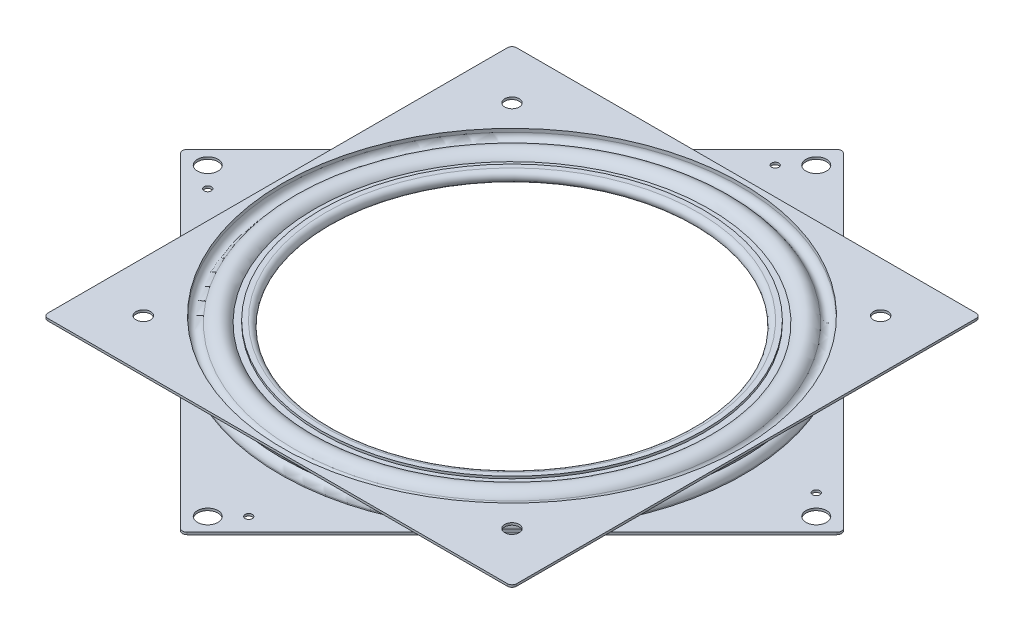
from build123d import *

# Parameters (mm, degrees)
BOSS_EXTRUDE1_START     = -0.7366
SKETCH4_W               = 153.924
SKETCH4_H               = 153.924
SKETCH4_R               = 75.348209056
BOSS_EXTRUDE1_DEPTH     = 0.7366
BOSS_EXTRUDE2_START     = -0.736601
SKETCH5_R               = 75.348209056
BOSS_EXTRUDE2_DEPTH     = 0.736602
SKETCH6_R               = 2.38125
CUT_EXTRUDE1_DEPTH      = 4.9370001
CUT_EXTRUDE1_DEPTH_BACK = 4.937001
SKETCH7_R               = 3.3734375
SKETCH7_R_2             = 1.1922125
CUT_EXTRUDE2_DEPTH      = 4.9370001
CUT_EXTRUDE2_DEPTH_BACK = 4.937001
CIRPATTERN1_COUNT       = 50
FILLET1_R               = 1.53924
FILLET2_R               = 1.53924


with BuildPart() as part:
    # Sketch3 → Revolve-Thin1 (revolve)
    with BuildSketch(Plane.XY):
        with BuildLine():
            Line((76.962, -3.937), (75.348209056, -3.937))
            Line((75.348209056, -3.937), (75.348209056, -2.83464))
            ThreePointArc((75.348209056, -2.83464), (73.867348091, -0.927495427), (71.652806037, -1.88976))
            ThreePointArc((71.652806037, -1.88976), (67.651879497, -3.898798296), (64.358457004, -0.86614))
            Line((64.358457004, -0.86614), (61.20765, -0.86614))
            ThreePointArc((61.20765, -0.86614), (59.436, 0.90551), (61.20765, 2.67716))
            Line((61.20765, 2.67716), (62.783053502, 2.67716))
            Line((62.783053502, 2.67716), (62.783053502, 1.94056))
            Line((62.783053502, 1.94056), (61.20765, 1.94056))
            ThreePointArc((61.20765, 1.94056), (60.1726, 0.90551), (61.20765, -0.12954))
            Line((61.20765, -0.12954), (65.001222718, -0.12954))
            ThreePointArc((65.001222718, -0.12954), (67.469119821, -3.116060828), (71.006610069, -1.536192))
            ThreePointArc((71.006610069, -1.536192), (74.049819472, -0.213854232), (76.084809056, -2.83464))
            Line((76.084809056, -2.83464), (76.084809056, -3.2004))
            Line((76.084809056, -3.2004), (76.962, -3.2004))
            Line((76.962, -3.2004), (76.962, -3.937))
        make_face()
    revolve(axis=Axis((0, 3.937, 0), (0, -1, 0)))

    # Sketch5 → Boss-Extrude2 (add)
    with BuildSketch(Plane.XZ.offset(3.937).offset(BOSS_EXTRUDE2_START)):
        Polygon((-108.840704187, 0), (0, 108.840704187), (108.840704187, 0), (0, -108.840704187), align=None)
        Circle(SKETCH5_R, mode=Mode.SUBTRACT)
    extrude(amount=BOSS_EXTRUDE2_DEPTH)

    # Sketch7 → Cut-Extrude2 (cut, two sides)
    with BuildSketch(Plane(origin=(0, 0, 0), x_dir=(1, 0, 0), z_dir=(0, 1, 0))) as cut_extrude2_sk:
        with Locations((99.905349347, 0)):
            Circle(SKETCH7_R)
        with Locations((0, 99.905349347)):
            Circle(SKETCH7_R)
        with Locations((-99.905349347, 0)):
            Circle(SKETCH7_R)
        with Locations((0, -99.905349347)):
            Circle(SKETCH7_R)
        with Locations((6.735192091, -93.170157256)):
            Circle(SKETCH7_R_2)
        with Locations((-93.170157256, -6.735192091)):
            Circle(SKETCH7_R_2)
        with Locations((-6.735192091, 93.170157256)):
            Circle(SKETCH7_R_2)
        with Locations((93.170157256, 6.735192091)):
            Circle(SKETCH7_R_2)
    extrude(amount=CUT_EXTRUDE2_DEPTH, mode=Mode.SUBTRACT)
    extrude(cut_extrude2_sk.sketch, amount=-CUT_EXTRUDE2_DEPTH_BACK, mode=Mode.SUBTRACT)

    # Fillet2
    fillet2_edges = [part.edges().sort_by_distance(p)[0] for p in [
        (0, -3.5687, -108.840704187),
        (-108.840704187, -3.5687, 0),
        (0, -3.5687, 108.840704187),
        (108.840704187, -3.5687, 0),
    ]]
    fillet(fillet2_edges, radius=FILLET2_R)


with BuildPart() as body_2:
    # Sketch3_3 → Revolve-Thin2 (revolve)
    with BuildSketch(Plane.XY):
        with BuildLine():
            Line((76.962, 3.937), (75.348209056, 3.937))
            Line((75.348209056, 3.937), (75.348209056, 2.83464))
            ThreePointArc((75.348209056, 2.83464), (73.867348091, 0.927495427), (71.652806037, 1.88976))
            ThreePointArc((71.652806037, 1.88976), (68.228071759, 3.936892662), (64.773478742, 1.94056))
            Line((64.773478742, 1.94056), (61.20765, 1.94056))
            Line((61.20765, 1.94056), (61.20765, 1.20396))
            Line((61.20765, 1.20396), (65.233693864, 1.20396))
            ThreePointArc((65.233693864, 1.20396), (68.015120861, 3.195113241), (71.006610069, 1.536192))
            ThreePointArc((71.006610069, 1.536192), (74.049819472, 0.213854232), (76.084809056, 2.83464))
            Line((76.084809056, 2.83464), (76.084809056, 3.2004))
            Line((76.084809056, 3.2004), (76.962, 3.2004))
            Line((76.962, 3.2004), (76.962, 3.937))
        make_face()
    revolve(axis=Axis((0, 3.937, 0), (0, -1, 0)))

    # Sketch4 → Boss-Extrude1 (add)
    with BuildSketch(Plane(origin=(0, 3.937, 0), x_dir=(1, 0, 0), z_dir=(0, 1, 0)).offset(BOSS_EXTRUDE1_START)):
        Rectangle(SKETCH4_W, SKETCH4_H)
        Circle(SKETCH4_R, mode=Mode.SUBTRACT)
    extrude(amount=BOSS_EXTRUDE1_DEPTH)

    # Sketch6 → Cut-Extrude1 (cut, two sides)
    with BuildSketch(Plane(origin=(0, 0, 0), x_dir=(1, 0, 0), z_dir=(0, 1, 0))) as cut_extrude1_sk:
        with Locations((-60.5282, 60.5282)):
            Circle(SKETCH6_R)
        with Locations((-60.5282, -60.5282)):
            Circle(SKETCH6_R)
        with Locations((60.5282, -60.5282)):
            Circle(SKETCH6_R)
        with Locations((60.5282, 60.5282)):
            Circle(SKETCH6_R)
    extrude(amount=CUT_EXTRUDE1_DEPTH, mode=Mode.SUBTRACT)
    extrude(cut_extrude1_sk.sketch, amount=-CUT_EXTRUDE1_DEPTH_BACK, mode=Mode.SUBTRACT)

    # Fillet1
    fillet1_edges = [body_2.edges().sort_by_distance(p)[0] for p in [
        (-76.962, 3.5687, 76.962),
        (-76.962, 3.5687, -76.962),
        (76.962, 3.5687, -76.962),
        (76.962, 3.5687, 76.962),
    ]]
    fillet(fillet1_edges, radius=FILLET1_R)


with BuildPart() as body_3:
    # Sketch8 → Revolve1 (revolve)
    with BuildSketch(Plane.XY):
        with BuildLine():
            Line((68.199, -3.683), (68.199, 3.683))
            ThreePointArc((68.199, 3.683), (71.882, 0), (68.199, -3.683))
        make_face()
    revolve(axis=Axis((68.199, -3.683, 0), (0, 1, 0)))


with BuildPart() as cirpattern1_1:
    # CirPattern1: pattern copy
    add(body_3.part.rotate(Axis((0, 0, 0), (0, 1, 0)), 1 * 360 / CIRPATTERN1_COUNT))


with BuildPart() as cirpattern1_2:
    # CirPattern1: pattern copy
    add(body_3.part.rotate(Axis((0, 0, 0), (0, 1, 0)), 2 * 360 / CIRPATTERN1_COUNT))


with BuildPart() as cirpattern1_3:
    # CirPattern1: pattern copy
    add(body_3.part.rotate(Axis((0, 0, 0), (0, 1, 0)), 3 * 360 / CIRPATTERN1_COUNT))


with BuildPart() as cirpattern1_4:
    # CirPattern1: pattern copy
    add(body_3.part.rotate(Axis((0, 0, 0), (0, 1, 0)), 4 * 360 / CIRPATTERN1_COUNT))


with BuildPart() as cirpattern1_5:
    # CirPattern1: pattern copy
    add(body_3.part.rotate(Axis((0, 0, 0), (0, 1, 0)), 5 * 360 / CIRPATTERN1_COUNT))


with BuildPart() as cirpattern1_6:
    # CirPattern1: pattern copy
    add(body_3.part.rotate(Axis((0, 0, 0), (0, 1, 0)), 6 * 360 / CIRPATTERN1_COUNT))


with BuildPart() as cirpattern1_7:
    # CirPattern1: pattern copy
    add(body_3.part.rotate(Axis((0, 0, 0), (0, 1, 0)), 7 * 360 / CIRPATTERN1_COUNT))


with BuildPart() as cirpattern1_8:
    # CirPattern1: pattern copy
    add(body_3.part.rotate(Axis((0, 0, 0), (0, 1, 0)), 8 * 360 / CIRPATTERN1_COUNT))


with BuildPart() as cirpattern1_9:
    # CirPattern1: pattern copy
    add(body_3.part.rotate(Axis((0, 0, 0), (0, 1, 0)), 9 * 360 / CIRPATTERN1_COUNT))


with BuildPart() as cirpattern1_10:
    # CirPattern1: pattern copy
    add(body_3.part.rotate(Axis((0, 0, 0), (0, 1, 0)), 10 * 360 / CIRPATTERN1_COUNT))


with BuildPart() as cirpattern1_11:
    # CirPattern1: pattern copy
    add(body_3.part.rotate(Axis((0, 0, 0), (0, 1, 0)), 11 * 360 / CIRPATTERN1_COUNT))


with BuildPart() as cirpattern1_12:
    # CirPattern1: pattern copy
    add(body_3.part.rotate(Axis((0, 0, 0), (0, 1, 0)), 12 * 360 / CIRPATTERN1_COUNT))


with BuildPart() as cirpattern1_13:
    # CirPattern1: pattern copy
    add(body_3.part.rotate(Axis((0, 0, 0), (0, 1, 0)), 13 * 360 / CIRPATTERN1_COUNT))


with BuildPart() as cirpattern1_14:
    # CirPattern1: pattern copy
    add(body_3.part.rotate(Axis((0, 0, 0), (0, 1, 0)), 14 * 360 / CIRPATTERN1_COUNT))


with BuildPart() as cirpattern1_15:
    # CirPattern1: pattern copy
    add(body_3.part.rotate(Axis((0, 0, 0), (0, 1, 0)), 15 * 360 / CIRPATTERN1_COUNT))


with BuildPart() as cirpattern1_16:
    # CirPattern1: pattern copy
    add(body_3.part.rotate(Axis((0, 0, 0), (0, 1, 0)), 16 * 360 / CIRPATTERN1_COUNT))


with BuildPart() as cirpattern1_17:
    # CirPattern1: pattern copy
    add(body_3.part.rotate(Axis((0, 0, 0), (0, 1, 0)), 17 * 360 / CIRPATTERN1_COUNT))


with BuildPart() as cirpattern1_18:
    # CirPattern1: pattern copy
    add(body_3.part.rotate(Axis((0, 0, 0), (0, 1, 0)), 18 * 360 / CIRPATTERN1_COUNT))


with BuildPart() as cirpattern1_19:
    # CirPattern1: pattern copy
    add(body_3.part.rotate(Axis((0, 0, 0), (0, 1, 0)), 19 * 360 / CIRPATTERN1_COUNT))


with BuildPart() as cirpattern1_20:
    # CirPattern1: pattern copy
    add(body_3.part.rotate(Axis((0, 0, 0), (0, 1, 0)), 20 * 360 / CIRPATTERN1_COUNT))


with BuildPart() as cirpattern1_21:
    # CirPattern1: pattern copy
    add(body_3.part.rotate(Axis((0, 0, 0), (0, 1, 0)), 21 * 360 / CIRPATTERN1_COUNT))


with BuildPart() as cirpattern1_22:
    # CirPattern1: pattern copy
    add(body_3.part.rotate(Axis((0, 0, 0), (0, 1, 0)), 22 * 360 / CIRPATTERN1_COUNT))


with BuildPart() as cirpattern1_23:
    # CirPattern1: pattern copy
    add(body_3.part.rotate(Axis((0, 0, 0), (0, 1, 0)), 23 * 360 / CIRPATTERN1_COUNT))


with BuildPart() as cirpattern1_24:
    # CirPattern1: pattern copy
    add(body_3.part.rotate(Axis((0, 0, 0), (0, 1, 0)), 24 * 360 / CIRPATTERN1_COUNT))


with BuildPart() as cirpattern1_25:
    # CirPattern1: pattern copy
    add(body_3.part.rotate(Axis((0, 0, 0), (0, 1, 0)), 25 * 360 / CIRPATTERN1_COUNT))


with BuildPart() as cirpattern1_26:
    # CirPattern1: pattern copy
    add(body_3.part.rotate(Axis((0, 0, 0), (0, 1, 0)), 26 * 360 / CIRPATTERN1_COUNT))


with BuildPart() as cirpattern1_27:
    # CirPattern1: pattern copy
    add(body_3.part.rotate(Axis((0, 0, 0), (0, 1, 0)), 27 * 360 / CIRPATTERN1_COUNT))


with BuildPart() as cirpattern1_28:
    # CirPattern1: pattern copy
    add(body_3.part.rotate(Axis((0, 0, 0), (0, 1, 0)), 28 * 360 / CIRPATTERN1_COUNT))


with BuildPart() as cirpattern1_29:
    # CirPattern1: pattern copy
    add(body_3.part.rotate(Axis((0, 0, 0), (0, 1, 0)), 29 * 360 / CIRPATTERN1_COUNT))


with BuildPart() as cirpattern1_30:
    # CirPattern1: pattern copy
    add(body_3.part.rotate(Axis((0, 0, 0), (0, 1, 0)), 30 * 360 / CIRPATTERN1_COUNT))


with BuildPart() as cirpattern1_31:
    # CirPattern1: pattern copy
    add(body_3.part.rotate(Axis((0, 0, 0), (0, 1, 0)), 31 * 360 / CIRPATTERN1_COUNT))


with BuildPart() as cirpattern1_32:
    # CirPattern1: pattern copy
    add(body_3.part.rotate(Axis((0, 0, 0), (0, 1, 0)), 32 * 360 / CIRPATTERN1_COUNT))


with BuildPart() as cirpattern1_33:
    # CirPattern1: pattern copy
    add(body_3.part.rotate(Axis((0, 0, 0), (0, 1, 0)), 33 * 360 / CIRPATTERN1_COUNT))


with BuildPart() as cirpattern1_34:
    # CirPattern1: pattern copy
    add(body_3.part.rotate(Axis((0, 0, 0), (0, 1, 0)), 34 * 360 / CIRPATTERN1_COUNT))


with BuildPart() as cirpattern1_35:
    # CirPattern1: pattern copy
    add(body_3.part.rotate(Axis((0, 0, 0), (0, 1, 0)), 35 * 360 / CIRPATTERN1_COUNT))


with BuildPart() as cirpattern1_36:
    # CirPattern1: pattern copy
    add(body_3.part.rotate(Axis((0, 0, 0), (0, 1, 0)), 36 * 360 / CIRPATTERN1_COUNT))


with BuildPart() as cirpattern1_37:
    # CirPattern1: pattern copy
    add(body_3.part.rotate(Axis((0, 0, 0), (0, 1, 0)), 37 * 360 / CIRPATTERN1_COUNT))


with BuildPart() as cirpattern1_38:
    # CirPattern1: pattern copy
    add(body_3.part.rotate(Axis((0, 0, 0), (0, 1, 0)), 38 * 360 / CIRPATTERN1_COUNT))


with BuildPart() as cirpattern1_39:
    # CirPattern1: pattern copy
    add(body_3.part.rotate(Axis((0, 0, 0), (0, 1, 0)), 39 * 360 / CIRPATTERN1_COUNT))


with BuildPart() as cirpattern1_40:
    # CirPattern1: pattern copy
    add(body_3.part.rotate(Axis((0, 0, 0), (0, 1, 0)), 40 * 360 / CIRPATTERN1_COUNT))


with BuildPart() as cirpattern1_41:
    # CirPattern1: pattern copy
    add(body_3.part.rotate(Axis((0, 0, 0), (0, 1, 0)), 41 * 360 / CIRPATTERN1_COUNT))


with BuildPart() as cirpattern1_42:
    # CirPattern1: pattern copy
    add(body_3.part.rotate(Axis((0, 0, 0), (0, 1, 0)), 42 * 360 / CIRPATTERN1_COUNT))


with BuildPart() as cirpattern1_43:
    # CirPattern1: pattern copy
    add(body_3.part.rotate(Axis((0, 0, 0), (0, 1, 0)), 43 * 360 / CIRPATTERN1_COUNT))


with BuildPart() as cirpattern1_44:
    # CirPattern1: pattern copy
    add(body_3.part.rotate(Axis((0, 0, 0), (0, 1, 0)), 44 * 360 / CIRPATTERN1_COUNT))


with BuildPart() as cirpattern1_45:
    # CirPattern1: pattern copy
    add(body_3.part.rotate(Axis((0, 0, 0), (0, 1, 0)), 45 * 360 / CIRPATTERN1_COUNT))


with BuildPart() as cirpattern1_46:
    # CirPattern1: pattern copy
    add(body_3.part.rotate(Axis((0, 0, 0), (0, 1, 0)), 46 * 360 / CIRPATTERN1_COUNT))


with BuildPart() as cirpattern1_47:
    # CirPattern1: pattern copy
    add(body_3.part.rotate(Axis((0, 0, 0), (0, 1, 0)), 47 * 360 / CIRPATTERN1_COUNT))


with BuildPart() as cirpattern1_48:
    # CirPattern1: pattern copy
    add(body_3.part.rotate(Axis((0, 0, 0), (0, 1, 0)), 48 * 360 / CIRPATTERN1_COUNT))


with BuildPart() as cirpattern1_49:
    # CirPattern1: pattern copy
    add(body_3.part.rotate(Axis((0, 0, 0), (0, 1, 0)), 49 * 360 / CIRPATTERN1_COUNT))


solid = Compound([part.part, body_2.part, body_3.part, cirpattern1_1.part, cirpattern1_2.part, cirpattern1_3.part, cirpattern1_4.part, cirpattern1_5.part, cirpattern1_6.part, cirpattern1_7.part, cirpattern1_8.part, cirpattern1_9.part, cirpattern1_10.part, cirpattern1_11.part, cirpattern1_12.part, cirpattern1_13.part, cirpattern1_14.part, cirpattern1_15.part, cirpattern1_16.part, cirpattern1_17.part, cirpattern1_18.part, cirpattern1_19.part, cirpattern1_20.part, cirpattern1_21.part, cirpattern1_22.part, cirpattern1_23.part, cirpattern1_24.part, cirpattern1_25.part, cirpattern1_26.part, cirpattern1_27.part, cirpattern1_28.part, cirpattern1_29.part, cirpattern1_30.part, cirpattern1_31.part, cirpattern1_32.part, cirpattern1_33.part, cirpattern1_34.part, cirpattern1_35.part, cirpattern1_36.part, cirpattern1_37.part, cirpattern1_38.part, cirpattern1_39.part, cirpattern1_40.part, cirpattern1_41.part, cirpattern1_42.part, cirpattern1_43.part, cirpattern1_44.part, cirpattern1_45.part, cirpattern1_46.part, cirpattern1_47.part, cirpattern1_48.part, cirpattern1_49.part])
